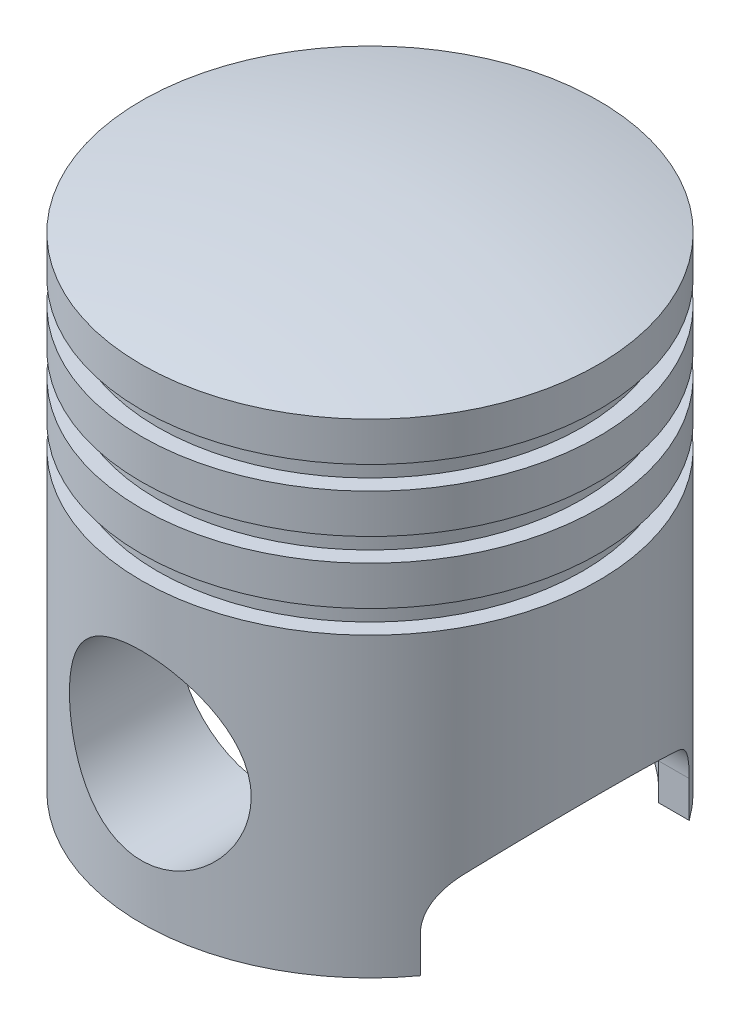
from build123d import *

# Parameters (mm, degrees)
SKETCH1_R                = 1079.5
BOSS_EXTRUDE1_DEPTH      = 2286
CUT_EXTRUDE1_START       = -185.42
SKETCH2_OUTSIDE_W        = 2923.846
SKETCH2_OUTSIDE_H        = 2923.846
SKETCH2_OUTSIDE_R        = 1003.3
CUT_EXTRUDE1_DEPTH       = 109.22
LPATTERN2_COUNT          = 3
LPATTERN2_PITCH          = 294.64
DOME1_FACE_RADIUS        = 1079.5
DOME1_HEIGHT             = 127
SKETCH3_R                = 965.2
CUT_EXTRUDE2_DEPTH       = 2159
SKETCH4_R                = 429.26
CUT_EXTRUDE3_DEPTH       = 2856.382548801
CUT_EXTRUDE3_DEPTH_BACK  = 2856.382548801
CUT_EXTRUDE5_DEPTH       = 2856.382548877
CUT_EXTRUDE5_DEPTH_BACK  = 2856.382548877
FILLET1_R                = 254
BOSS_EXTRUDE2_REACH      = 3339.983
BOSS_EXTRUDE2_END_RADIUS = 965.2
BOSS_EXTRUDE2_START      = 482.6
SKETCH8_R                = 571.5
SKETCH8_R_2              = 429.26


with BuildPart() as part:
    # Sketch1 → Boss-Extrude1 (new body)
    with BuildSketch(Plane(origin=(0, 0, 0), x_dir=(1, 0, 0), z_dir=(0, 1, 0))):
        with Locations(Location((0, 0, 0), (0, 0, 270))):
            Circle(SKETCH1_R)
    extrude(amount=BOSS_EXTRUDE1_DEPTH)

    # Sketch2 outside → Cut-Extrude1 (cut)
    with BuildSketch(Plane(origin=(0, 2286, 0), x_dir=(1, 0, 0), z_dir=(0, 1, 0)).offset(CUT_EXTRUDE1_START)):
        Rectangle(SKETCH2_OUTSIDE_W, SKETCH2_OUTSIDE_H)
        with Locations(Location((0, 0, 0), (0, 0, 270))):
            Circle(SKETCH2_OUTSIDE_R, mode=Mode.SUBTRACT)
    cut_extrude1 = extrude(amount=-CUT_EXTRUDE1_DEPTH, mode=Mode.SUBTRACT)

    # LPattern2: Cut-Extrude1 ×3
    with Locations(*[(0, -i * LPATTERN2_PITCH, 0) for i in range(1, LPATTERN2_COUNT)]):
        add(cut_extrude1, mode=Mode.SUBTRACT)

    # Dome1: a dome of height H over a round flat face of radius A is a cap of a sphere of radius (A * A + H * H) / (2 * H)
    dome1_r = (DOME1_FACE_RADIUS * DOME1_FACE_RADIUS + DOME1_HEIGHT * DOME1_HEIGHT) / (2 * DOME1_HEIGHT)
    dome1_base = Plane((0, 2286, 0), z_dir=(0, 1, 0))
    with Locations(dome1_base.offset(DOME1_HEIGHT - dome1_r)):
        dome1_ball = Sphere(dome1_r, mode=Mode.PRIVATE)
    add(split(dome1_ball, bisect_by=dome1_base, keep=Keep.TOP, mode=Mode.PRIVATE))

    # Sketch3 → Cut-Extrude2 (cut)
    with BuildSketch(Plane.XZ):
        with Locations(Location((0, 0, 0), (0, 0, 270))):
            Circle(SKETCH3_R)
    extrude(amount=-CUT_EXTRUDE2_DEPTH, mode=Mode.SUBTRACT)

    # Sketch4 → Cut-Extrude3 (cut, two sides)
    with BuildSketch(Plane.XY) as cut_extrude3_sk:
        with Locations((0, 685.8)):
            Circle(SKETCH4_R)
    extrude(amount=CUT_EXTRUDE3_DEPTH, mode=Mode.SUBTRACT)
    extrude(cut_extrude3_sk.sketch, amount=-CUT_EXTRUDE3_DEPTH_BACK, mode=Mode.SUBTRACT)

    # Sketch7 → Cut-Extrude5 (cut, two sides)
    with BuildSketch(Plane(origin=(0, 0, 0), x_dir=(0, 0, -1), z_dir=(1, 0, 0))) as cut_extrude5_sk:
        with BuildLine():
            Line((-635, 304.8), (-635, 0))
            Line((-635, 0), (635, 0))
            Line((635, 0), (635, 304.8))
            ThreePointArc((635, 304.8), (0, 527.685254203), (-635, 304.8))
        make_face()
    extrude(amount=CUT_EXTRUDE5_DEPTH, mode=Mode.SUBTRACT)
    extrude(cut_extrude5_sk.sketch, amount=-CUT_EXTRUDE5_DEPTH_BACK, mode=Mode.SUBTRACT)

    # Fillet1
    fillet1_edges = [part.edges().sort_by_distance(p)[0] for p in [
        (-799.941170684, 304.8, 635),
        (799.941170684, 304.8, 635),
        (799.941170684, 304.8, -635),
        (-799.941170684, 304.8, -635),
    ]]
    fillet(fillet1_edges, radius=FILLET1_R)

    # Boss-Extrude2: up to this cylinder (the profile starts inside it)
    boss_extrude2_end = Plane(origin=(0, 685.8, 0), z_dir=(0, -1, 0)) * Cylinder(BOSS_EXTRUDE2_END_RADIUS, 8611.366, mode=Mode.PRIVATE)
    # Sketch8 → Boss-Extrude2 (add, up to the surface)
    with BuildSketch(Plane.XY.offset(BOSS_EXTRUDE2_START), mode=Mode.PRIVATE) as boss_extrude2_sk1:
        with Locations(Location((0, 685.8, 0), (0, 0, 180))):
            Circle(SKETCH8_R)
        with Locations((0, 685.8)):
            Circle(SKETCH8_R_2, mode=Mode.SUBTRACT)
    boss_extrude2_tool1 = extrude(boss_extrude2_sk1.sketch, amount=BOSS_EXTRUDE2_REACH, mode=Mode.PRIVATE) & boss_extrude2_end
    boss_extrude2 = boss_extrude2_tool1.solids().sort_by_distance((555.335539, 685.8, 482.6))[0]
    add(boss_extrude2)

    # Mirror1: Boss-Extrude2 across plane
    add(boss_extrude2.mirror(Plane.XY))


solid = part.part
